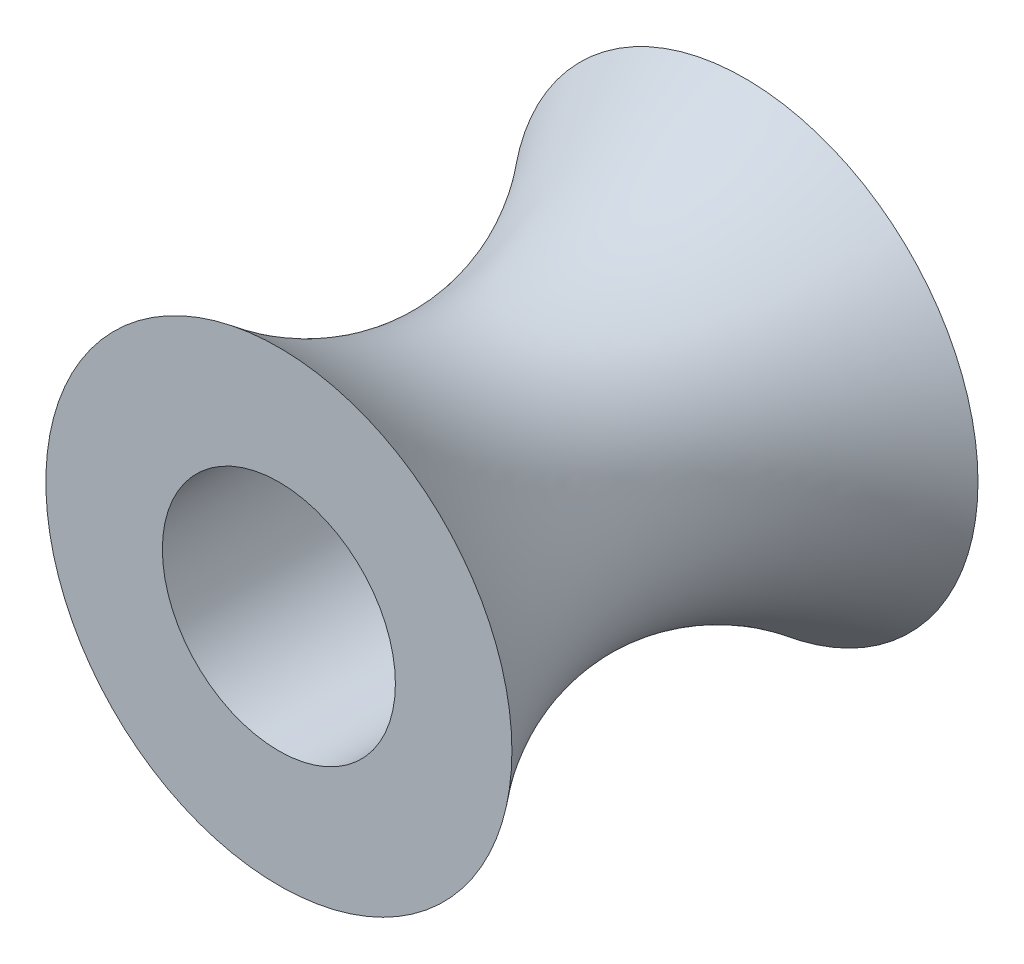
from build123d import *

# Parameters (mm, degrees)
SKETCH1_R           = 5
BOSS_EXTRUDE1_DEPTH = 10
SKETCH3_R           = 2.5
CUT_EXTRUDE1_DEPTH  = 11.0000001


with BuildPart() as part:
    # Sketch1 → Boss-Extrude1 (new body)
    with BuildSketch(Plane.XY):
        Circle(SKETCH1_R)
    extrude(amount=BOSS_EXTRUDE1_DEPTH)

    # Sketch2 → Cut-Revolve1 (revolve, cut)
    with BuildSketch(Plane(origin=(0, 0, 0), x_dir=(0, 0, -1), z_dir=(1, 0, 0))):
        with BuildLine():
            Line((-10, 5), (0, 5))
            add(Edge.make_bspline(
                [(-10, 5), (-4.983047183, 0.999551108), (0, 5)],
                knots=[0, 0, 0, 1, 1, 1], degree=2))
        make_face()
    revolve(axis=Axis((0, 0, 13.970265117), (0, 0, -1)), mode=Mode.SUBTRACT)

    # Sketch3 → Cut-Extrude1 (cut, through all)
    with BuildSketch(Plane.XY.offset(10)):
        Circle(SKETCH3_R)
    extrude(amount=-CUT_EXTRUDE1_DEPTH, mode=Mode.SUBTRACT)


solid = part.part
